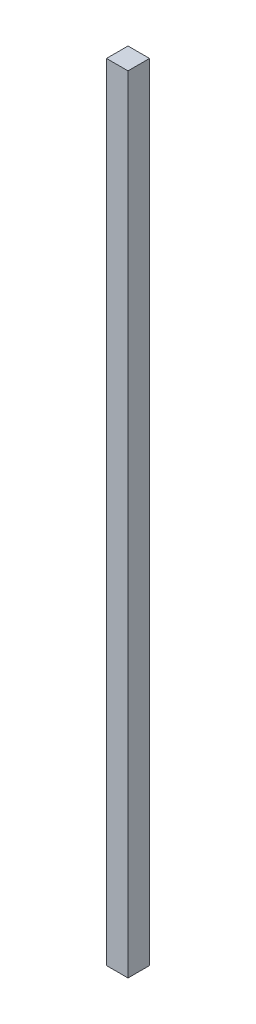
from build123d import *

# Parameters (mm, degrees)
SKETCH1_W           = 25.4
SKETCH1_H           = 25.4
BOSS_EXTRUDE1_DEPTH = 927.1


with BuildPart() as part:
    # Sketch1 → Boss-Extrude1 (new body)
    with BuildSketch(Plane(origin=(0, 0, 0), x_dir=(1, 0, 0), z_dir=(0, 1, 0))):
        with Locations((-27.135508984, 5.913615805)):
            Rectangle(SKETCH1_W, SKETCH1_H)
    extrude(amount=BOSS_EXTRUDE1_DEPTH)


solid = part.part
